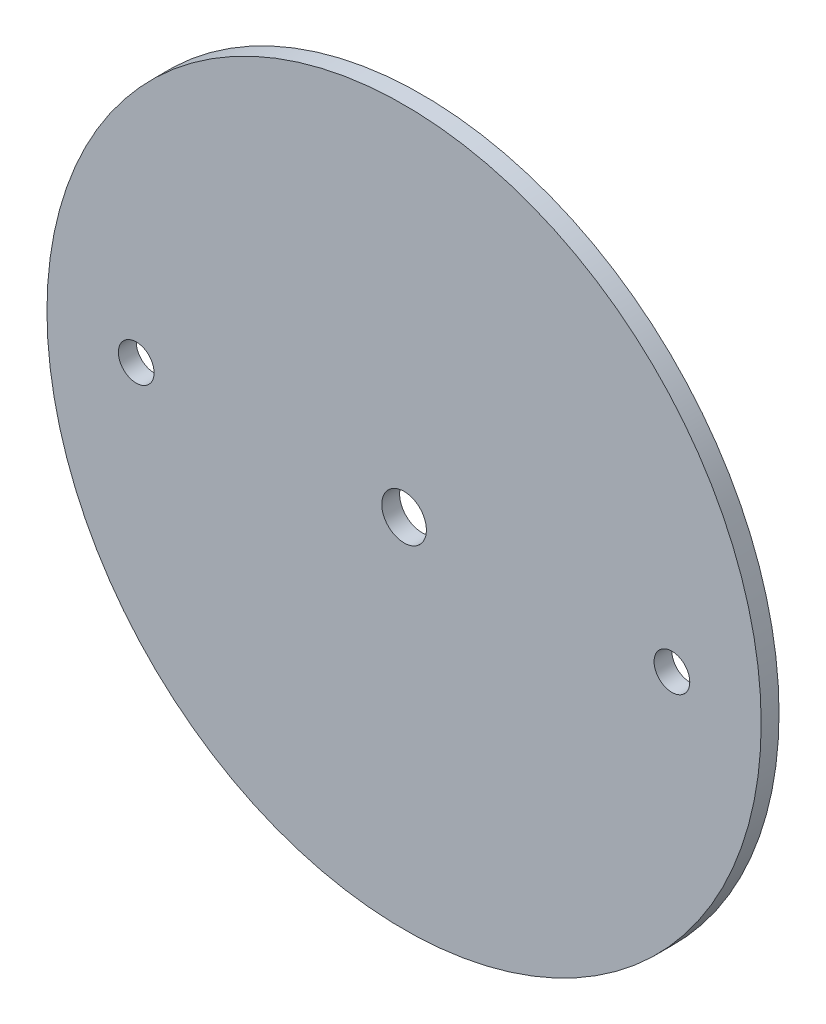
from build123d import *

# Parameters (mm, degrees)
SKETCH1_R                          = 63.5
BOSS_EXTRUDE1_DEPTH                = 1.5875
F_1_4_0_25_DIAMETER_HOLE1_D        = 6.35
F_5_16_0_3125_DIAMETER_HOLE1_D     = 7.9375
F_5_16_0_3125_DIAMETER_HOLE1_DEPTH = 3.302


with BuildPart() as part:
    # Sketch1 → Boss-Extrude1 (new body, symmetric)
    with BuildSketch(Plane.XY):
        Circle(SKETCH1_R)
    extrude(amount=BOSS_EXTRUDE1_DEPTH, both=True)

    # 1/4 (0.25) Diameter Hole1 (through all)
    with Locations(Plane.XY.offset(1.5875)):
        with Locations((-47.625, 0), (47.625, 0)):
            Hole(F_1_4_0_25_DIAMETER_HOLE1_D / 2)

    # 5/16 (0.3125) Diameter Hole1
    with Locations(Plane.XY.offset(1.5875)):
        with Locations((0, 0)):
            Hole(F_5_16_0_3125_DIAMETER_HOLE1_D / 2, depth=F_5_16_0_3125_DIAMETER_HOLE1_DEPTH)


solid = part.part
